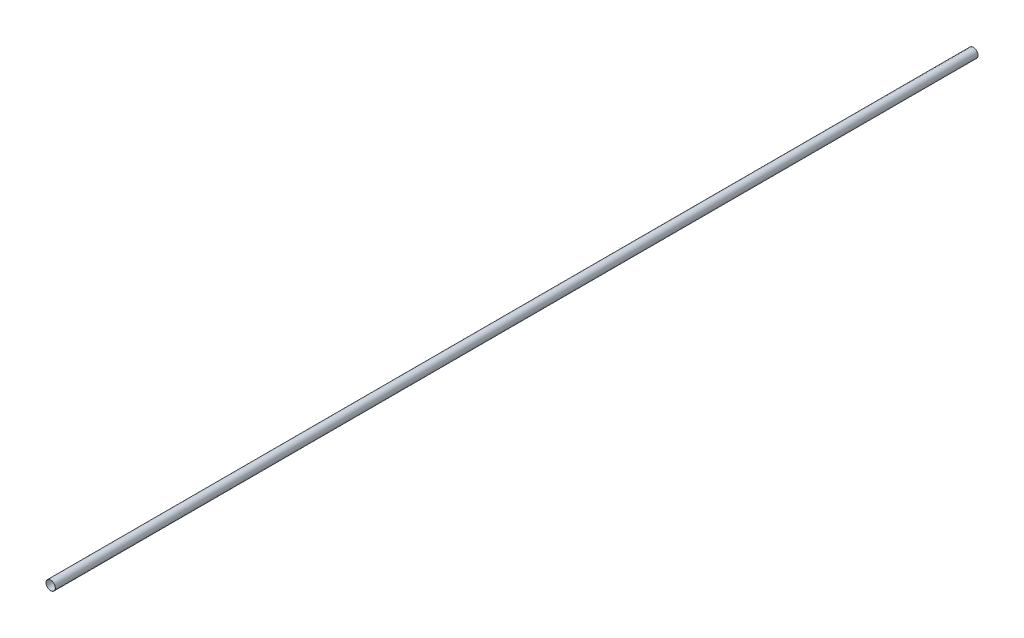
from build123d import *

# Parameters (mm, degrees)
SKETCH1_R           = 101
SKETCH1_R_2         = 100
BOSS_EXTRUDE1_DEPTH = 20000


with BuildPart() as part:
    # Sketch1 → Boss-Extrude1 (new body)
    with BuildSketch(Plane.XY):
        Circle(SKETCH1_R)
        Circle(SKETCH1_R_2, mode=Mode.SUBTRACT)
    extrude(amount=BOSS_EXTRUDE1_DEPTH)


solid = part.part
